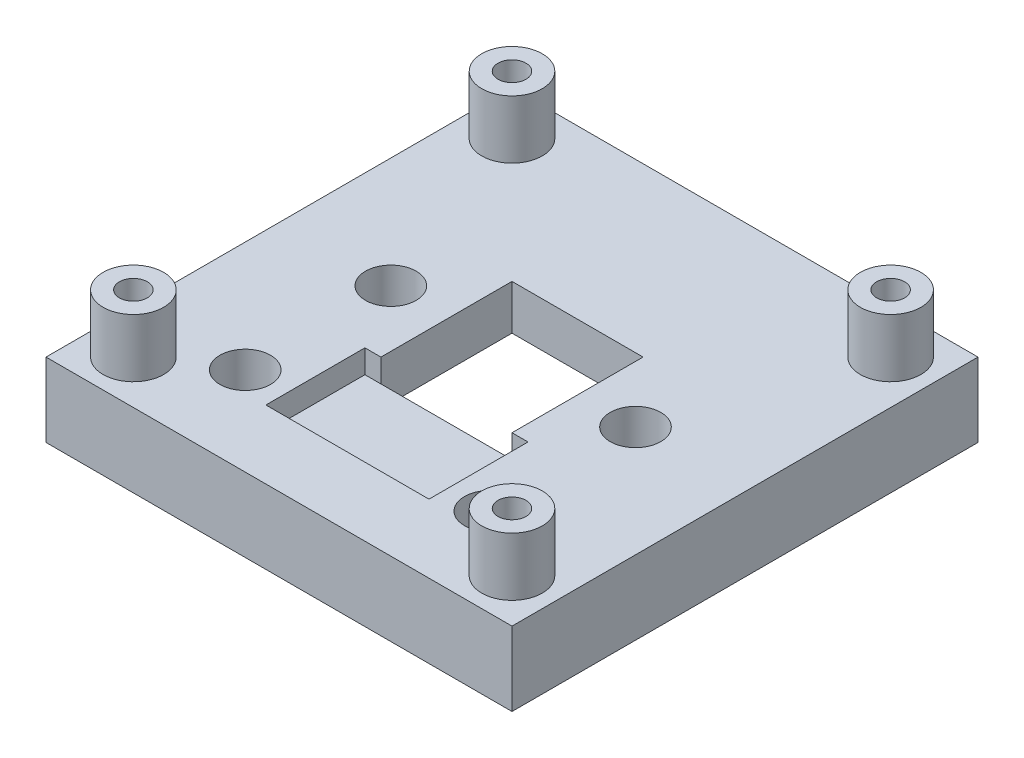
from build123d import *

# Parameters (mm, degrees)
SKETCH1_W                      = 40
SKETCH1_H                      = 40
BOSS_EXTRUDE1_DEPTH            = 6.35
SKETCH2_W                      = 11.25
SKETCH2_H                      = 11.25
CUT_EXTRUDE1_DEPTH             = 7.35
SKETCH3_W                      = 14
SKETCH3_H                      = 8.5
CUT_EXTRUDE2_DEPTH             = 2
M2_CLEARANCE_HOLE1_D           = 2.4
SKETCH6_R                      = 2.6
BOSS_EXTRUDE2_DEPTH            = 5
CBORE_FOR_M2_SHCS1_D           = 2.4
CBORE_FOR_M2_SHCS1_CBORE_D     = 4.4
CBORE_FOR_M2_SHCS1_CBORE_DEPTH = 2
SKETCH13_R                     = 2.175
CUT_EXTRUDE4_DEPTH             = 4.2
CHAMFER1_SIZE                  = 2.5


with BuildPart() as part:
    # Sketch1 → Boss-Extrude1 (new body)
    with BuildSketch(Plane(origin=(0, 0, 0), x_dir=(1, 0, 0), z_dir=(0, 1, 0))):
        Rectangle(SKETCH1_W, SKETCH1_H)
    extrude(amount=BOSS_EXTRUDE1_DEPTH)

    # Sketch2 → Cut-Extrude1 (cut, through all)
    with BuildSketch(Plane(origin=(0, 6.35, 0), x_dir=(1, 0, 0), z_dir=(0, 1, 0))):
        Rectangle(SKETCH2_W, SKETCH2_H)
    extrude(amount=-CUT_EXTRUDE1_DEPTH, mode=Mode.SUBTRACT)

    # Sketch3 → Cut-Extrude2 (cut)
    with BuildSketch(Plane(origin=(0, 6.35, 0), x_dir=(1, 0, 0), z_dir=(0, 1, 0))):
        with Locations((0, -9.875)):
            Rectangle(SKETCH3_W, SKETCH3_H)
    extrude(amount=-CUT_EXTRUDE2_DEPTH, mode=Mode.SUBTRACT)

    # M2 Clearance Hole1 (through all)
    with Locations(Plane(origin=(0, 6.35, 0), x_dir=(1, 0, 0), z_dir=(0, 1, 0))):
        with Locations((10.5, 0.1), (10.5, -12.4), (-10.5, -12.4), (-10.5, 0.1)):
            Hole(M2_CLEARANCE_HOLE1_D / 2)

    # Sketch6 → Boss-Extrude2 (add)
    with BuildSketch(Plane(origin=(0, 6.35, 0), x_dir=(1, 0, 0), z_dir=(0, 1, 0))):
        with Locations((-16.25, 16.25)):
            Circle(SKETCH6_R)
        with Locations((16.25, 16.25)):
            Circle(SKETCH6_R)
        with Locations((16.25, -16.25)):
            Circle(SKETCH6_R)
        with Locations((-16.25, -16.25)):
            Circle(SKETCH6_R)
    extrude(amount=BOSS_EXTRUDE2_DEPTH)

    # CBORE for M2 SHCS1 (through all)
    with Locations(Plane.XZ):
        with Locations((-16.25, -16.25), (-16.25, 16.25), (16.25, 16.25), (16.25, -16.25)):
            CounterBoreHole(CBORE_FOR_M2_SHCS1_D / 2, CBORE_FOR_M2_SHCS1_CBORE_D / 2, CBORE_FOR_M2_SHCS1_CBORE_DEPTH)

    # Sketch13 → Cut-Extrude4 (cut)
    with BuildSketch(Plane(origin=(0, 6.35, 0), x_dir=(1, 0, 0), z_dir=(0, 1, 0))):
        with Locations((-10.5, -12.4)):
            Circle(SKETCH13_R)
        with Locations((-10.5, 0.1)):
            Circle(SKETCH13_R)
        with Locations((10.5, -12.4)):
            Circle(SKETCH13_R)
        with Locations((10.5, 0.1)):
            Circle(SKETCH13_R)
    extrude(amount=-CUT_EXTRUDE4_DEPTH, mode=Mode.SUBTRACT)

    # Chamfer1
    chamfer1_edges = [part.edges().sort_by_distance(p)[0] for p in [
        (5.625, 0, 0),
        (0, 0, 5.625),
        (-5.625, 0, 0),
        (0, 0, -5.625),
    ]]
    chamfer(chamfer1_edges, length=CHAMFER1_SIZE)


solid = part.part
